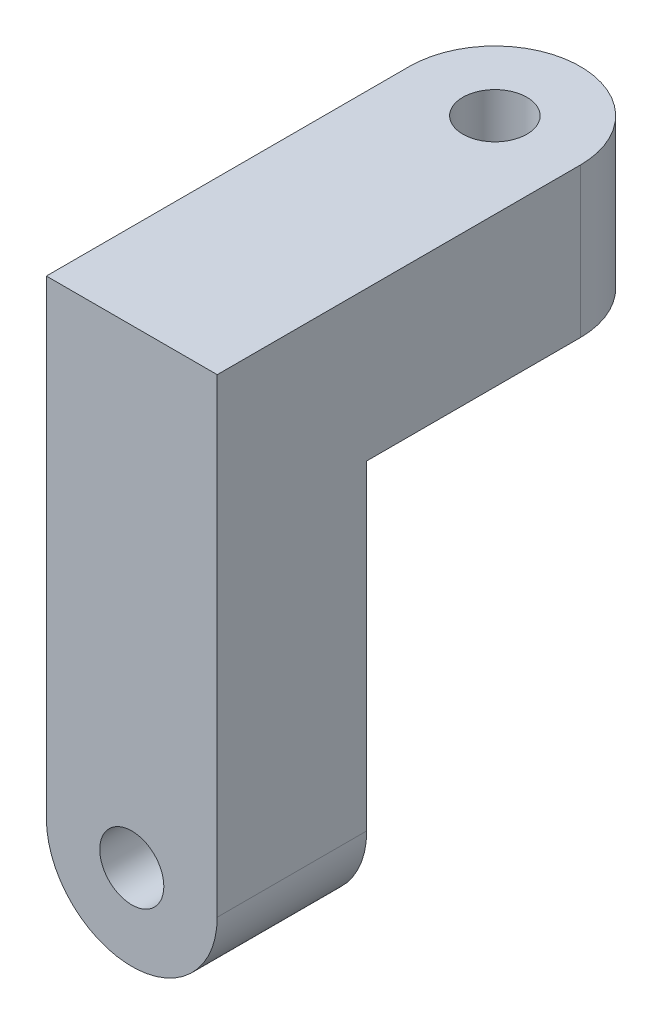
from build123d import *

# Parameters (mm, degrees)
SKETCH2_R           = 1.5
BOSS_EXTRUDE1_DEPTH = 7
SKETCH3_R           = 1.5
BOSS_EXTRUDE2_DEPTH = 7


with BuildPart() as part:
    # Sketch2 → Boss-Extrude1 (new body)
    with BuildSketch(Plane.XY):
        with BuildLine():
            Line((-4, -15), (-4, 0))
            Line((-4, 0), (4, 0))
            Line((4, 0), (4, -15))
            ThreePointArc((4, -15), (0, -19), (-4, -15))
        make_face()
        with Locations((0, -15)):
            Circle(SKETCH2_R, mode=Mode.SUBTRACT)
    extrude(amount=BOSS_EXTRUDE1_DEPTH)

    # Sketch3 → Boss-Extrude2 (add)
    with BuildSketch(Plane(origin=(0, 0, 0), x_dir=(1, 0, 0), z_dir=(0, 1, 0))):
        with BuildLine():
            Line((-4, 10), (-4, -7))
            Line((-4, -7), (4, -7))
            Line((4, -7), (4, 10))
            ThreePointArc((4, 10), (0, 14), (-4, 10))
        make_face()
        with Locations((0, 10)):
            Circle(SKETCH3_R, mode=Mode.SUBTRACT)
    extrude(amount=BOSS_EXTRUDE2_DEPTH)


solid = part.part
